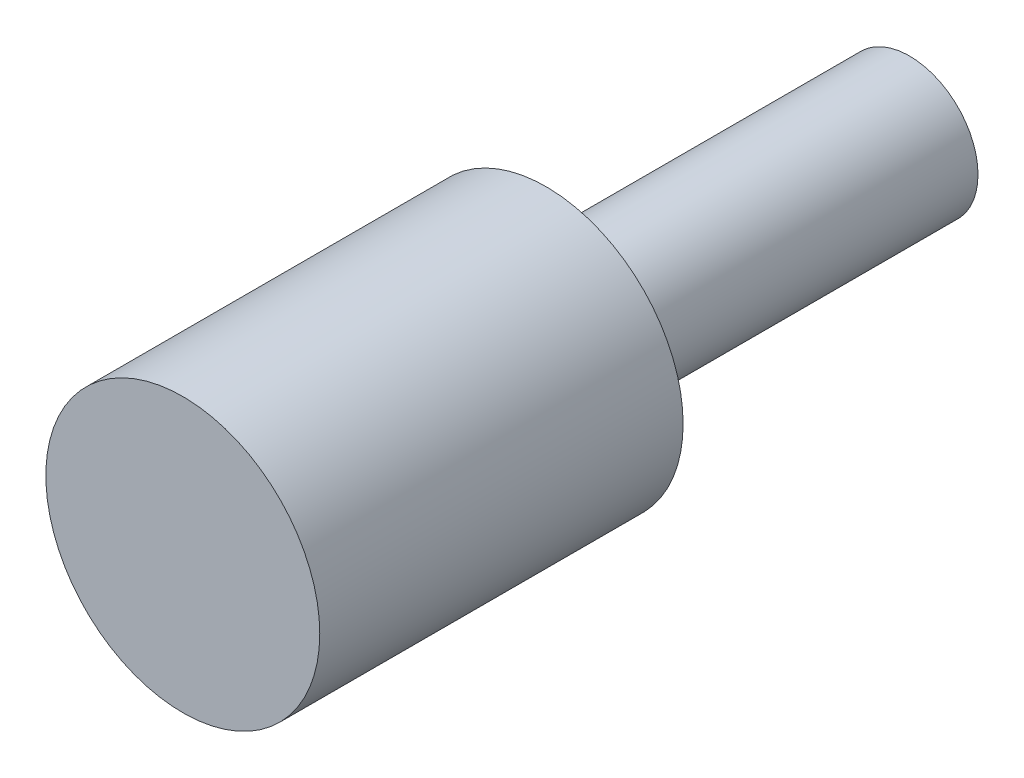
from build123d import *

# Parameters (mm, degrees)
SKETCH1_R           = 6.223
BOSS_EXTRUDE1_DEPTH = 33.02
SKETCH2_R           = 12.446
BOSS_EXTRUDE2_DEPTH = 33.02


with BuildPart() as part:
    # Sketch1 → Boss-Extrude1 (new body)
    with BuildSketch(Plane.XY):
        Circle(SKETCH1_R)
    extrude(amount=BOSS_EXTRUDE1_DEPTH)

    # Sketch2 → Boss-Extrude2 (add)
    with BuildSketch(Plane.XY.offset(33.02)):
        Circle(SKETCH2_R)
    extrude(amount=BOSS_EXTRUDE2_DEPTH)


solid = part.part
